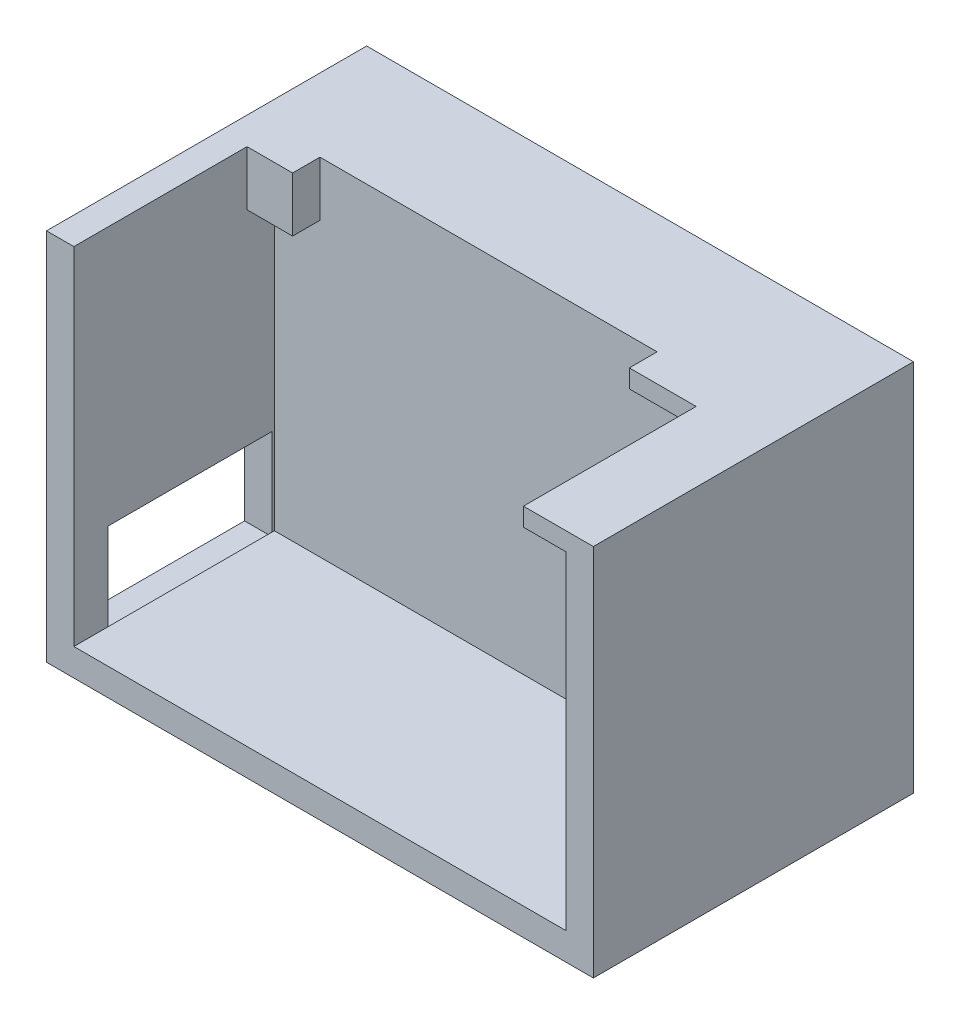
from build123d import *

# Parameters (mm, degrees)
ESQUISSE1_W             = 60
ESQUISSE1_H             = 42
BOSS_EXTRU_1_DEPTH      = 35.125
COQUE4_T                = -3
ESQUISSE7_W             = 54
ESQUISSE7_H             = 36
BOSS_EXTRU_2_DEPTH      = 10.125
ESQUISSE8_W             = 60
ESQUISSE8_H             = 35.125
ENL_V_MAT_EXTRU_1_DEPTH = 1
ESQUISSE9_W             = 10
ESQUISSE9_H             = 22
BOSS_EXTRU_3_DEPTH      = 1
ESQUISSE10_W            = 18
ESQUISSE10_H            = 10
ENL_V_MAT_EXTRU_2_DEPTH = 3
ESQUISSE13_W            = 42
ESQUISSE13_H            = 22
ENL_V_MAT_EXTRU_3_DEPTH = 10
ESQUISSE15_W            = 7.326333239
ESQUISSE15_H            = 18.950794871
ENL_V_MAT_EXTRU_4_DEPTH = 4
ESQUISSE16_W            = 5
ESQUISSE16_H            = 6
BOSS_EXTRU_4_DEPTH      = 3


with BuildPart() as part:
    # Esquisse1 → Boss.-Extru.1 (new body)
    with BuildSketch(Plane.XY):
        with Locations((30, 21)):
            Rectangle(ESQUISSE1_W, ESQUISSE1_H)
    extrude(amount=BOSS_EXTRU_1_DEPTH)

    # Coque4
    coque4_openings = [part.faces().sort_by_distance(p)[0] for p in [
        (30, 21, 35.125),
    ]]
    offset(amount=COQUE4_T, openings=coque4_openings, kind=Kind.INTERSECTION)

    # Esquisse7 → Boss.-Extru.2 (add)
    with BuildSketch(Plane.XY.offset(3)):
        with Locations((30, 21)):
            Rectangle(ESQUISSE7_W, ESQUISSE7_H)
    extrude(amount=BOSS_EXTRU_2_DEPTH)

    # Esquisse8 → Enlèv. mat.-Extru.1 (cut)
    with BuildSketch(Plane(origin=(0, 42, 0), x_dir=(1, 0, 0), z_dir=(0, 1, 0))):
        with Locations((30, -17.5625)):
            Rectangle(ESQUISSE8_W, ESQUISSE8_H)
    extrude(amount=-ENL_V_MAT_EXTRU_1_DEPTH, mode=Mode.SUBTRACT)

    # Esquisse9 → Boss.-Extru.3 (add)
    with BuildSketch(Plane(origin=(0, 41, 0), x_dir=(1, 0, 0), z_dir=(0, 1, 0))):
        with Locations((55, -24.125)):
            Rectangle(ESQUISSE9_W, ESQUISSE9_H)
    extrude(amount=-BOSS_EXTRU_3_DEPTH)

    # Esquisse10 → Enlèv. mat.-Extru.2 (cut)
    with BuildSketch(Plane.ZY):
        with Locations((22.395110195, 7.568318588)):
            Rectangle(ESQUISSE10_W, ESQUISSE10_H)
    extrude(amount=-ENL_V_MAT_EXTRU_2_DEPTH, mode=Mode.SUBTRACT)

    # Esquisse13 → Enlèv. mat.-Extru.3 (cut)
    with BuildSketch(Plane(origin=(0, 39, 0), x_dir=(-1, 0, 0), z_dir=(0, -1, 0))):
        with Locations((-24, -24.125)):
            Rectangle(ESQUISSE13_W, ESQUISSE13_H)
    extrude(amount=-ENL_V_MAT_EXTRU_3_DEPTH, mode=Mode.SUBTRACT)

    # Esquisse15 → Enlèv. mat.-Extru.4 (cut)
    with BuildSketch(Plane(origin=(0, 41, 0), x_dir=(1, 0, 0), z_dir=(0, 1, 0))):
        with Locations((48.66316662, -25.649602565)):
            Rectangle(ESQUISSE15_W, ESQUISSE15_H)
    extrude(amount=-ENL_V_MAT_EXTRU_4_DEPTH, mode=Mode.SUBTRACT)

    # Esquisse16 → Boss.-Extru.4 (add)
    with BuildSketch(Plane.XY.offset(13.125)):
        with Locations((5.5, 38)):
            Rectangle(ESQUISSE16_W, ESQUISSE16_H)
    extrude(amount=BOSS_EXTRU_4_DEPTH)


solid = part.part
